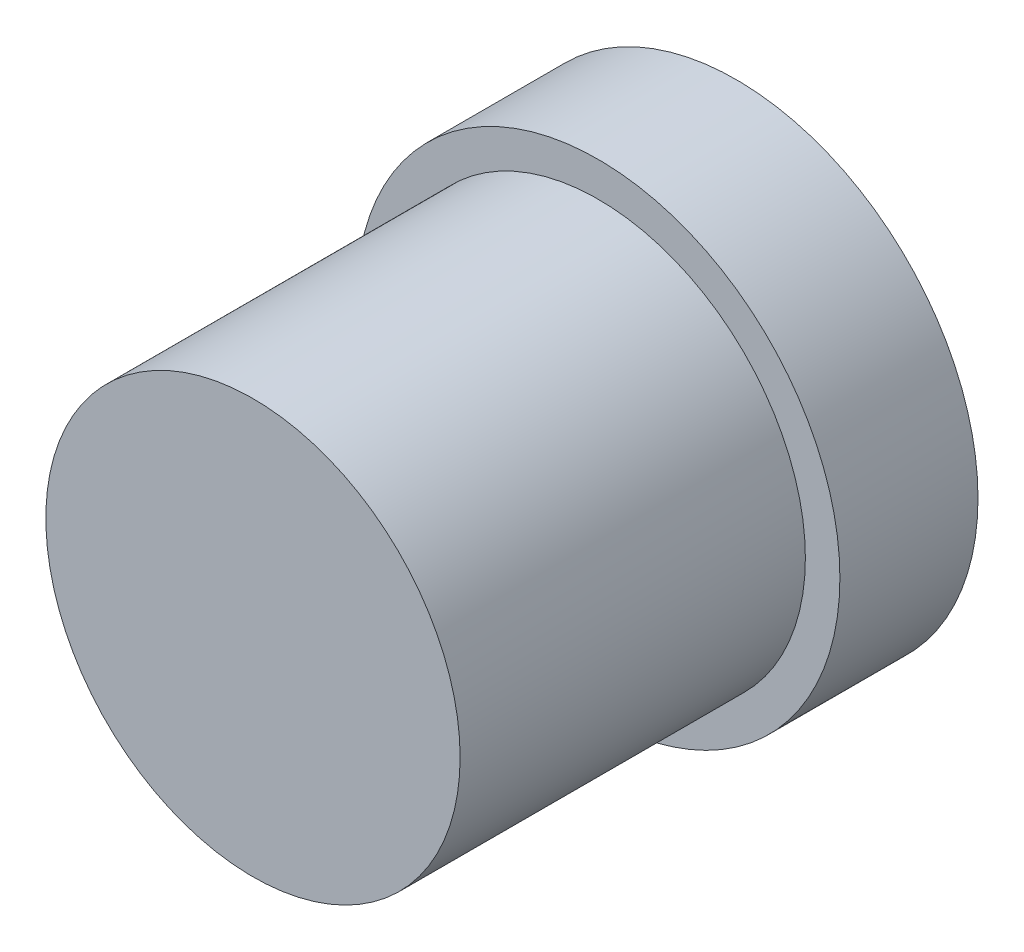
from build123d import *

# Parameters (mm, degrees)
SKETCH1_R           = 7
BOSS_EXTRUDE1_DEPTH = 4
SKETCH2_R           = 6
BOSS_EXTRUDE2_DEPTH = 10


with BuildPart() as part:
    # Sketch1 → Boss-Extrude1 (new body)
    with BuildSketch(Plane.XY):
        Circle(SKETCH1_R)
    extrude(amount=BOSS_EXTRUDE1_DEPTH)

    # Sketch2 → Boss-Extrude2 (add)
    with BuildSketch(Plane.XY.offset(4)):
        Circle(SKETCH2_R)
    extrude(amount=BOSS_EXTRUDE2_DEPTH)


solid = part.part
